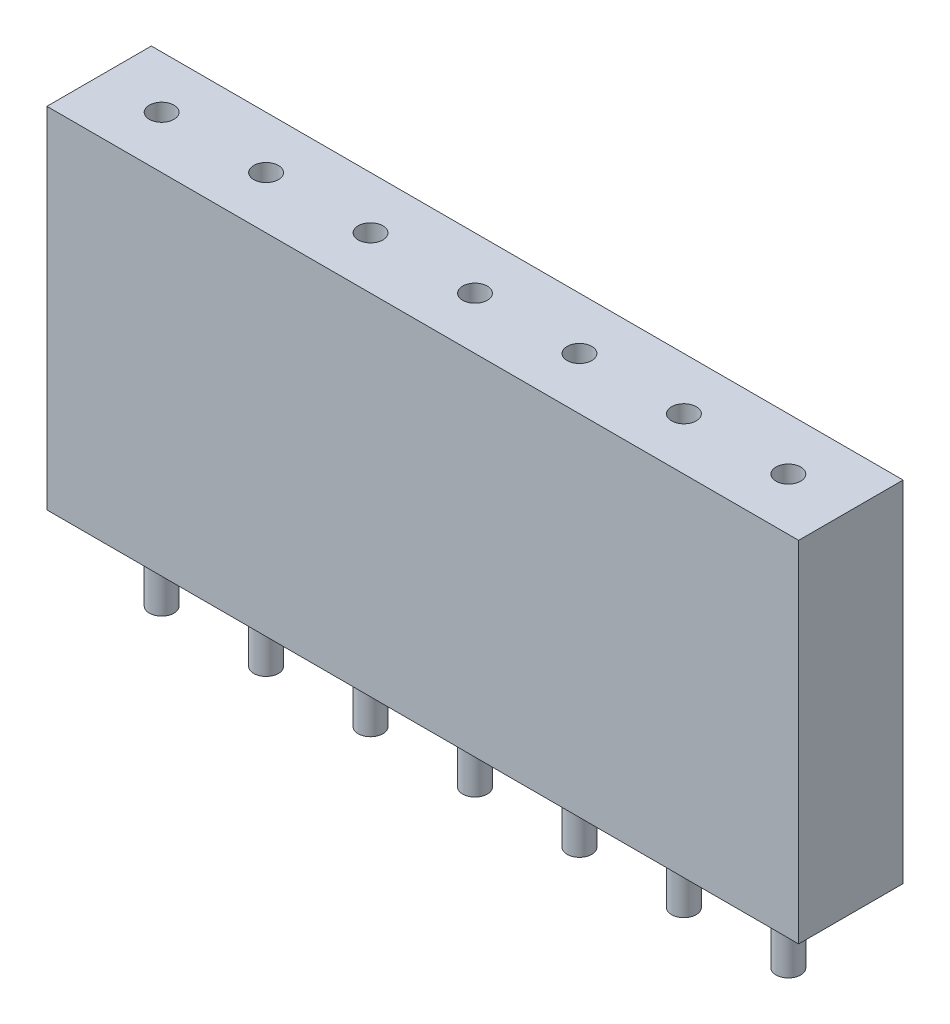
from build123d import *

# Parameters (mm, degrees)
SKETCH_1_W          = 18.28
SKETCH_1_H          = 2.54
EXTRUDE_1_DEPTH     = 8.5
SKETCH_2_R          = 0.3
CUT_EXTRUDE_1_DEPTH = 8.5
SKETCH_3_R          = 0.3
EXTRUDE_2_DEPTH     = 1.9
EXTRUDE_2_2_DEPTH   = 1.9
EXTRUDE_2_3_DEPTH   = 1.9
EXTRUDE_2_4_DEPTH   = 1.9
EXTRUDE_2_5_DEPTH   = 1.9
EXTRUDE_2_6_DEPTH   = 1.9
EXTRUDE_2_7_DEPTH   = 1.9


with BuildPart() as part:
    # Эскиз1 → Бобышка-Вытянуть1 (new body)
    with BuildSketch(Plane(origin=(0, 0, 0), x_dir=(1, 0, 0), z_dir=(0, 1, 0))):
        Rectangle(SKETCH_1_W, SKETCH_1_H)
    extrude(amount=EXTRUDE_1_DEPTH)

    # Эскиз2 → Вырез-Вытянуть1 (cut)
    with BuildSketch(Plane(origin=(0, 8.5, 0), x_dir=(1, 0, 0), z_dir=(0, 1, 0))):
        with Locations((-7.62, 0)):
            Circle(SKETCH_2_R)
        with Locations((-5.08, 0)):
            Circle(SKETCH_2_R)
        with Locations((-2.54, 0)):
            Circle(SKETCH_2_R)
        Circle(SKETCH_2_R)
        with Locations((2.54, 0)):
            Circle(SKETCH_2_R)
        with Locations((5.08, 0)):
            Circle(SKETCH_2_R)
        with Locations((7.62, 0)):
            Circle(SKETCH_2_R)
    extrude(amount=-CUT_EXTRUDE_1_DEPTH, mode=Mode.SUBTRACT)


with BuildPart() as body_2:
    # Эскиз3 → Бобышка-Вытянуть2 (new body)
    with BuildSketch(Plane.XZ):
        with Locations((-7.62, 0)):
            Circle(SKETCH_3_R)
    extrude(amount=EXTRUDE_2_DEPTH)


with BuildPart() as body_3:
    # Эскиз3 → Extrude 2 2 (new body)
    with BuildSketch(Plane.XZ):
        with Locations((-5.08, 0)):
            Circle(SKETCH_3_R)
    extrude(amount=EXTRUDE_2_2_DEPTH)


with BuildPart() as body_4:
    # Эскиз3 → Extrude 2 3 (new body)
    with BuildSketch(Plane.XZ):
        with Locations((-2.54, 0)):
            Circle(SKETCH_3_R)
    extrude(amount=EXTRUDE_2_3_DEPTH)


with BuildPart() as body_5:
    # Эскиз3 → Extrude 2 4 (new body)
    with BuildSketch(Plane.XZ):
        Circle(SKETCH_3_R)
    extrude(amount=EXTRUDE_2_4_DEPTH)


with BuildPart() as body_6:
    # Эскиз3 → Extrude 2 5 (new body)
    with BuildSketch(Plane.XZ):
        with Locations((2.54, 0)):
            Circle(SKETCH_3_R)
    extrude(amount=EXTRUDE_2_5_DEPTH)


with BuildPart() as body_7:
    # Эскиз3 → Extrude 2 6 (new body)
    with BuildSketch(Plane.XZ):
        with Locations((5.08, 0)):
            Circle(SKETCH_3_R)
    extrude(amount=EXTRUDE_2_6_DEPTH)


with BuildPart() as body_8:
    # Эскиз3 → Extrude 2 7 (new body)
    with BuildSketch(Plane.XZ):
        with Locations((7.62, 0)):
            Circle(SKETCH_3_R)
    extrude(amount=EXTRUDE_2_7_DEPTH)


solid = Compound([part.part, body_2.part, body_3.part, body_4.part, body_5.part, body_6.part, body_7.part, body_8.part])
